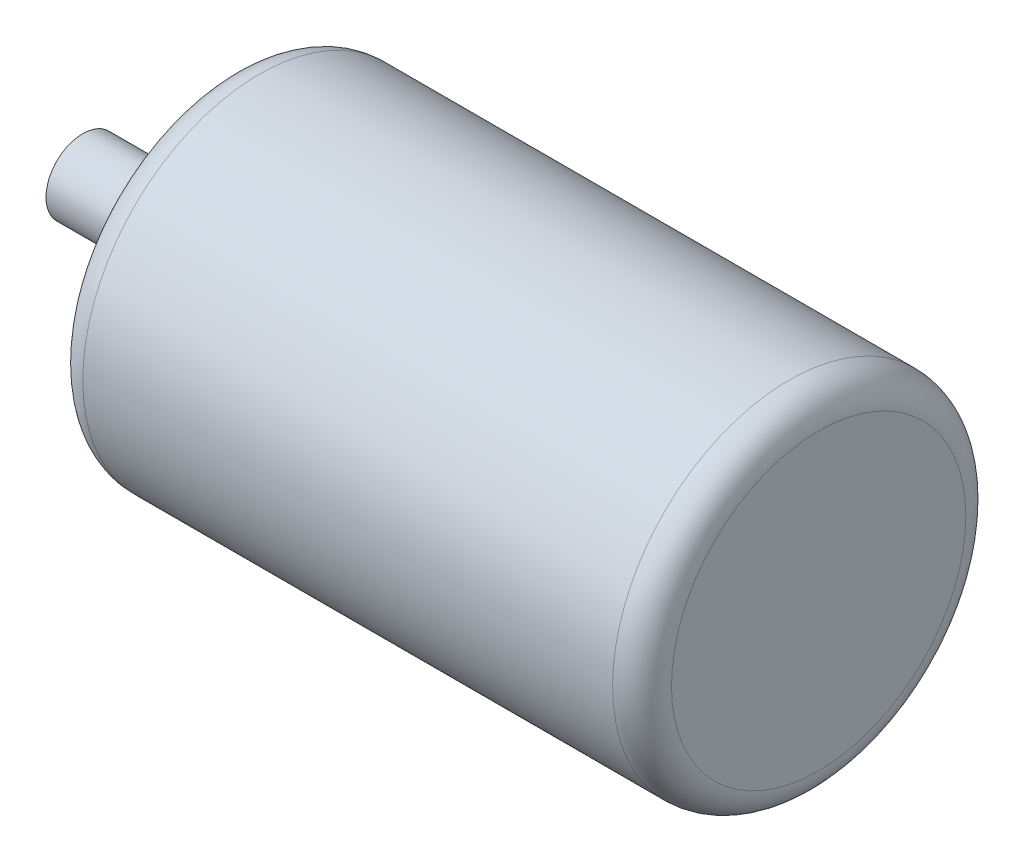
from build123d import *

# Parameters (mm, degrees)
SKETCH1_R                = 60
BOSS_EXTRUDE1_DEPTH      = 200
BOSS_EXTRUDE1_DEPTH_BACK = 50
SKETCH2_R                = 75
SKETCH2_R_2              = 12.5
CUT_EXTRUDE1_DEPTH       = 50
FILLET1_R                = 10


with BuildPart() as part:
    # Sketch1 → Boss-Extrude1 (new body, two sides)
    with BuildSketch(Plane(origin=(0, 0, 0), x_dir=(0, 0, -1), z_dir=(1, 0, 0))) as boss_extrude1_sk:
        Circle(SKETCH1_R)
    extrude(amount=BOSS_EXTRUDE1_DEPTH)
    extrude(boss_extrude1_sk.sketch, amount=-BOSS_EXTRUDE1_DEPTH_BACK)

    # Sketch2 → Cut-Extrude1 (cut)
    with BuildSketch(Plane.ZY.offset(50)):
        Circle(SKETCH2_R)
        Circle(SKETCH2_R_2, mode=Mode.SUBTRACT)
    extrude(amount=-CUT_EXTRUDE1_DEPTH, mode=Mode.SUBTRACT)

    # Fillet1
    fillet1_edges = [part.edges().sort_by_distance(p)[0] for p in [
        (0, 0, 60),
        (200, 0, 60),
    ]]
    fillet(fillet1_edges, radius=FILLET1_R)


solid = part.part
